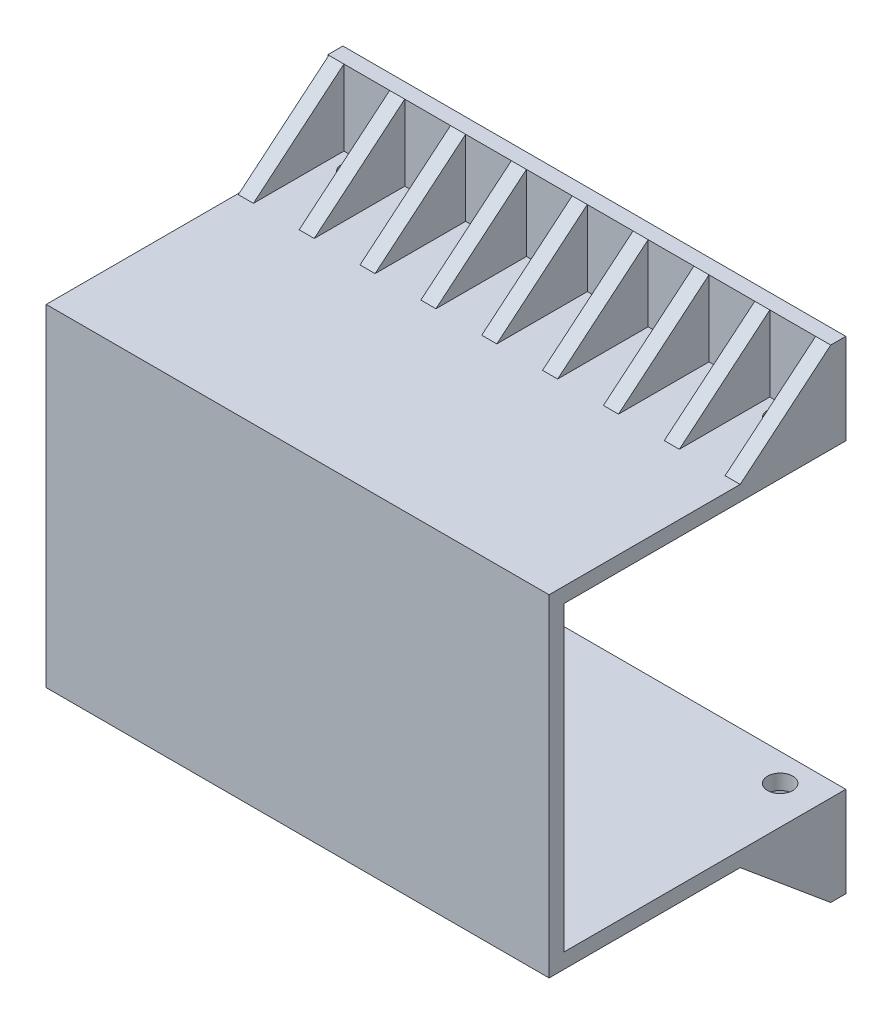
from build123d import *

# Parameters (mm, degrees)
SKETCH1_W                = 100
SKETCH1_H                = 60
BOSS_EXTRUDE1_DEPTH      = 3
SKETCH2_W                = 100
SKETCH2_H                = 3
BOSS_EXTRUDE2_DEPTH      = 53
BOSS_EXTRUDE2_DEPTH_BACK = 3
SKETCH3_W                = 100
SKETCH3_H                = 18
BOSS_EXTRUDE3_DEPTH      = 3
BOSS_EXTRUDE4_DEPTH      = 3
SKETCH6_W                = 97
SKETCH6_H                = 18
BOSS_EXTRUDE5_DEPTH      = 3
LPATTERN4_COUNT          = 9
LPATTERN4_PITCH          = 12.1
SKETCH7_R                = 2.5
CUT_EXTRUDE2_DEPTH       = 82
CUT_EXTRUDE4_DEPTH       = 101


with BuildPart() as part:
    # Sketch1 → Boss-Extrude1 (new body)
    with BuildSketch(Plane.XY):
        with Locations((50, 30)):
            Rectangle(SKETCH1_W, SKETCH1_H)
    extrude(amount=BOSS_EXTRUDE1_DEPTH)

    # Sketch2 → Boss-Extrude2 (add, two sides)
    with BuildSketch(Plane(origin=(0, 0, 0), x_dir=(-1, 0, 0), z_dir=(0, 0, -1))) as boss_extrude2_sk:
        with Locations((-50, 61.5)):
            Rectangle(SKETCH2_W, SKETCH2_H)
        with Locations((-50, -1.5)):
            Rectangle(SKETCH2_W, SKETCH2_H)
    extrude(amount=BOSS_EXTRUDE2_DEPTH)
    extrude(boss_extrude2_sk.sketch, amount=-BOSS_EXTRUDE2_DEPTH_BACK)

    # Sketch3 → Boss-Extrude3 (add)
    with BuildSketch(Plane(origin=(0, 0, -53), x_dir=(-1, 0, 0), z_dir=(0, 0, -1))):
        with Locations((-50, 69)):
            Rectangle(SKETCH3_W, SKETCH3_H)
        with Locations((-50, -9)):
            Rectangle(SKETCH3_W, SKETCH3_H)
    extrude(amount=BOSS_EXTRUDE3_DEPTH)

    # Sketch5 → Boss-Extrude4 (add)
    with BuildSketch(Plane(origin=(100, 0, 0), x_dir=(0, 0, -1), z_dir=(1, 0, 0))):
        Polygon((35, -3), (53, -3), (53, -18), align=None)
    boss_extrude4 = extrude(amount=-BOSS_EXTRUDE4_DEPTH)

    # Sketch6 → Boss-Extrude5 (add)
    with BuildSketch(Plane.XZ.offset(3)):
        with Locations((48.5, -44)):
            Rectangle(SKETCH6_W, SKETCH6_H)
    extrude(amount=-BOSS_EXTRUDE5_DEPTH)

    # LPattern4: Boss-Extrude4 ×9
    with Locations(*[(-i * LPATTERN4_PITCH, 0, 0) for i in range(1, LPATTERN4_COUNT)]):
        add(boss_extrude4)

    # Sketch7 → Cut-Extrude2 (cut, through all)
    with BuildSketch(Plane.XZ.offset(3)):
        with Locations((92.45, -50.5)):
            Circle(SKETCH7_R)
        with Locations((7.75, -50.5)):
            Circle(SKETCH7_R)
    extrude(amount=-CUT_EXTRUDE2_DEPTH, mode=Mode.SUBTRACT)

    # Sketch10 → Cut-Extrude4 (cut, through all)
    with BuildSketch(Plane.ZY):
        Polygon((0, 30), (3, 30), (3, 114.137691369), (-76.856579816, 109.737899985), (-70.799886201, 33.223019627), align=None)
    extrude(amount=-CUT_EXTRUDE4_DEPTH, mode=Mode.SUBTRACT)

    # Mirror2: part across plane


with BuildPart() as part_1:
    add(part.part)
    add(part.part.mirror(Plane(origin=(100, 30, 0), x_dir=(0, 0, 1), z_dir=(0, -1, 0))))


solid = part_1.part
